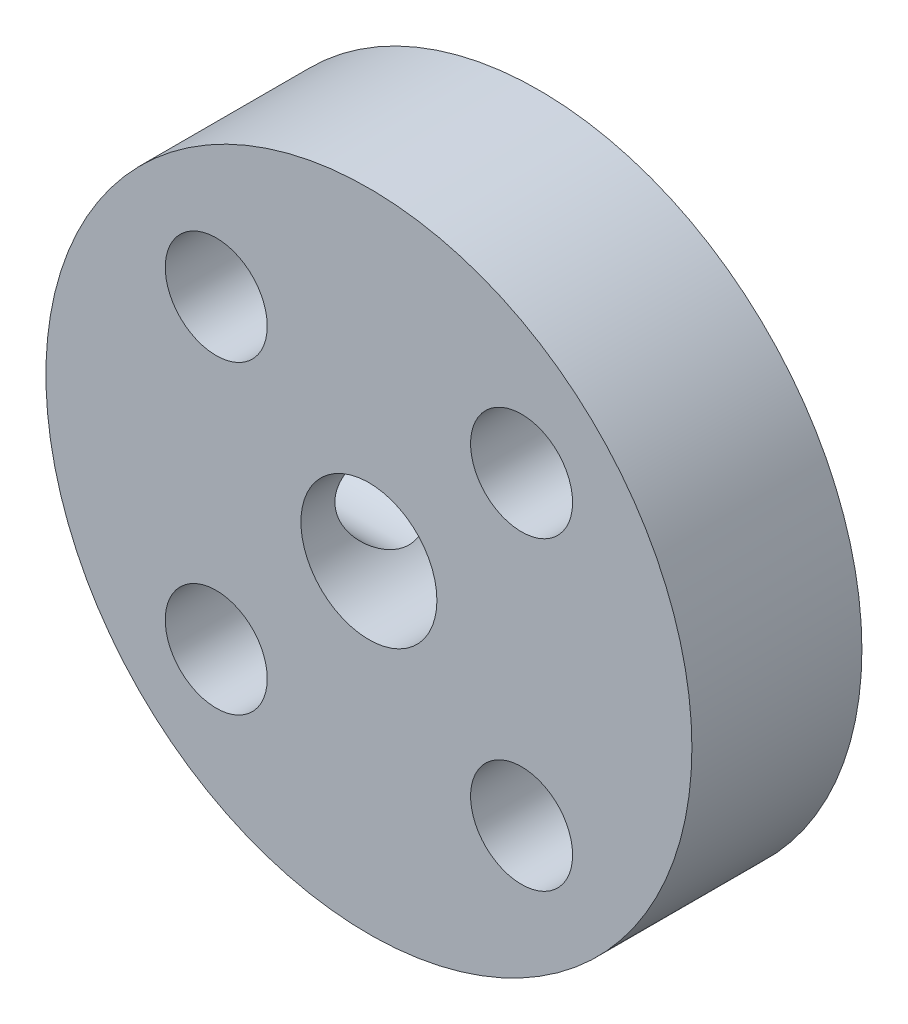
from build123d import *

# Parameters (mm, degrees)
ESQUISSE1_R             = 9.5
ESQUISSE1_R_2           = 2
ESQUISSE1_R_3           = 1.5
BOSS_EXTRU_1_DEPTH      = 2.5
ESQUISSE2_R             = 1.5
ENL_V_MAT_EXTRU_1_DEPTH = 16


with BuildPart() as part:
    # Esquisse1 → Boss.-Extru.1 (new body, symmetric)
    with BuildSketch(Plane.XY):
        Circle(ESQUISSE1_R)
        Circle(ESQUISSE1_R_2, mode=Mode.SUBTRACT)
        with Locations((4.490128061, 4.490128061)):
            Circle(ESQUISSE1_R_3, mode=Mode.SUBTRACT)
        with Locations((4.490128061, -4.490128061)):
            Circle(ESQUISSE1_R_3, mode=Mode.SUBTRACT)
        with Locations((-4.490128061, 4.490128061)):
            Circle(ESQUISSE1_R_3, mode=Mode.SUBTRACT)
        with Locations((-4.490128061, -4.490128061)):
            Circle(ESQUISSE1_R_3, mode=Mode.SUBTRACT)
    extrude(amount=BOSS_EXTRU_1_DEPTH, both=True)

    # Esquisse2 → Enlèv. mat.-Extru.1 (cut)
    with BuildSketch(Plane(origin=(0, 0, 0), x_dir=(0, 0, -1), z_dir=(1, 0, 0))):
        with Locations(Location((0, 0, 0), (0, 0, 180))):  # turned: the seam where the file's is
            Circle(ESQUISSE2_R)
    extrude(amount=-ENL_V_MAT_EXTRU_1_DEPTH, mode=Mode.SUBTRACT)


solid = part.part
